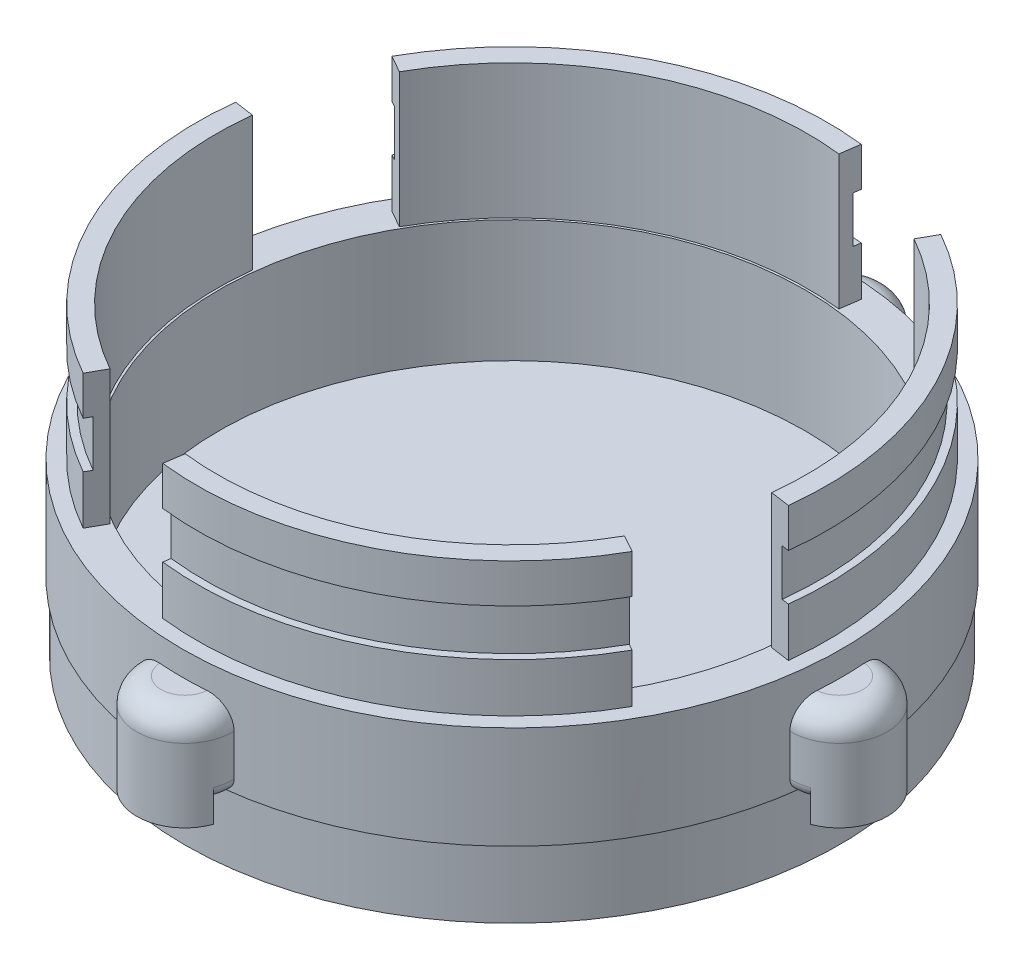
from build123d import *

# Parameters (mm, degrees)
SKETCH3_R             = 34.29
SKETCH3_R_2           = 30.48
BOSS_EXTRUDE2_DEPTH   = 12.7
BOSS_EXTRUDE6_DEPTH   = 26.67
BOSS_EXTRUDE6_2_DEPTH = 26.67
BOSS_EXTRUDE6_3_DEPTH = 26.67
BOSS_EXTRUDE6_4_DEPTH = 26.67
CUT_EXTRUDE2_START    = 17.78
SKETCH7_R             = 34.036
SKETCH7_R_2           = 32.004
CUT_EXTRUDE2_DEPTH    = 4.826
SKETCH8_R             = 34.036
SKETCH8_R_2           = 5
BOSS_EXTRUDE7_DEPTH   = 5.08
BOSS_EXTRUDE8_START   = 10.16
BOSS_EXTRUDE8_DEPTH   = 10.16
FILLET1_R             = 2.54
CUT_EXTRUDE3_START    = 2.032
SKETCH11_R            = 36.068
SKETCH11_R_2          = 34.036
CUT_EXTRUDE3_DEPTH    = 2.032
FILLET2_R             = 1.27


with BuildPart() as part:
    # Sketch3 → Boss-Extrude2 (new body)
    with BuildSketch(Plane(origin=(0, 0, 0), x_dir=(1, 0, 0), z_dir=(0, 1, 0))):
        with Locations(Location((0, 0, 0), (0, 0, 90))):
            Circle(SKETCH3_R)
        with Locations(Location((0, 0, 0), (0, 0, 90))):
            Circle(SKETCH3_R_2, mode=Mode.SUBTRACT)
    extrude(amount=BOSS_EXTRUDE2_DEPTH)



with BuildPart() as body_2:
    # Sketch5 → Boss-Extrude6 (new body)
    with BuildSketch(Plane(origin=(0, 0, 0), x_dir=(1, 0, 0), z_dir=(0, 1, 0))):
        with BuildLine():
            ThreePointArc((28.559021933, -16.062161195), (14.875452714, -29.194719772), (-3.792010539, -32.545835557))
            Line((-3.792010539, -32.545835557), (-3.498056233, -30.513835557))
            ThreePointArc((-3.498056233, -30.513835557), (13.96902765, -27.35318673), (26.770214716, -15.056100486))
            Line((26.770214716, -15.056100486), (28.559021933, -16.062161195))
        make_face()
    extrude(amount=BOSS_EXTRUDE6_DEPTH)


with BuildPart() as body_3:
    # Sketch5 → Boss-Extrude6 2 (new body)
    with BuildSketch(Plane(origin=(0, 0, 0), x_dir=(1, 0, 0), z_dir=(0, 1, 0))):
        with BuildLine():
            ThreePointArc((-28.559021933, 16.062161195), (-14.875452714, 29.194719772), (3.792010539, 32.545835557))
            Line((3.792010539, 32.545835557), (3.498056233, 30.513835557))
            ThreePointArc((3.498056233, 30.513835557), (-13.96902765, 27.35318673), (-26.770214716, 15.056100486))
            Line((-26.770214716, 15.056100486), (-28.559021933, 16.062161195))
        make_face()
    extrude(amount=BOSS_EXTRUDE6_2_DEPTH)


with BuildPart() as body_4:
    # Sketch5 → Boss-Extrude6 3 (new body)
    with BuildSketch(Plane(origin=(0, 0, 0), x_dir=(1, 0, 0), z_dir=(0, 1, 0))):
        with BuildLine():
            ThreePointArc((-16.062161195, -28.559021933), (-29.194719772, -14.875452714), (-32.545835557, 3.792010539))
            Line((-32.545835557, 3.792010539), (-30.513835557, 3.498056233))
            ThreePointArc((-30.513835557, 3.498056233), (-27.35318673, -13.96902765), (-15.056100486, -26.770214716))
            Line((-15.056100486, -26.770214716), (-16.062161195, -28.559021933))
        make_face()
    extrude(amount=BOSS_EXTRUDE6_3_DEPTH)


with BuildPart() as body_5:
    # Sketch5 → Boss-Extrude6 4 (new body)
    with BuildSketch(Plane(origin=(0, 0, 0), x_dir=(1, 0, 0), z_dir=(0, 1, 0))):
        with BuildLine():
            ThreePointArc((30.513835557, -3.498056233), (27.35318673, 13.96902765), (15.056100486, 26.770214716))
            Line((15.056100486, 26.770214716), (16.062161195, 28.559021933))
            ThreePointArc((16.062161195, 28.559021933), (29.194719772, 14.875452714), (32.545835557, -3.792010539))
            Line((32.545835557, -3.792010539), (30.513835557, -3.498056233))
        make_face()
    extrude(amount=BOSS_EXTRUDE6_4_DEPTH)


with BuildPart() as cut_extrude2_tool:
    # Sketch7 → Cut-Extrude2 (new body)
    with BuildSketch(Plane(origin=(0, 0, 0), x_dir=(1, 0, 0), z_dir=(0, 1, 0)).offset(CUT_EXTRUDE2_START)):
        Circle(SKETCH7_R)
        Circle(SKETCH7_R_2, mode=Mode.SUBTRACT)
    extrude(amount=CUT_EXTRUDE2_DEPTH)


with BuildPart() as body_2_1:
    add(body_2.part)

    # Cut-Extrude2: cut by cut_extrude2_tool
    add(cut_extrude2_tool.part, mode=Mode.SUBTRACT)


with BuildPart() as body_3_1:
    add(body_3.part)

    # Cut-Extrude2: cut by cut_extrude2_tool
    add(cut_extrude2_tool.part, mode=Mode.SUBTRACT)


with BuildPart() as body_4_1:
    add(body_4.part)

    # Cut-Extrude2: cut by cut_extrude2_tool
    add(cut_extrude2_tool.part, mode=Mode.SUBTRACT)


with BuildPart() as body_5_1:
    add(body_5.part)

    # Cut-Extrude2: cut by cut_extrude2_tool
    add(cut_extrude2_tool.part, mode=Mode.SUBTRACT)


with BuildPart() as part_1:
    add(part.part)

    add(body_2_1.part)  # Boss-Extrude7 merges body 2

    add(body_3_1.part)  # Boss-Extrude7 merges body 3

    add(body_4_1.part)  # Boss-Extrude7 merges body 4

    add(body_5_1.part)  # Boss-Extrude7 merges body 5
    # Sketch8 → Boss-Extrude7 (add)
    with BuildSketch(Plane(origin=(0, 0, 0), x_dir=(1, 0, 0), z_dir=(0, 1, 0))):
        with Locations(Location((0, 0, 0), (0, 0, 270))):
            Circle(SKETCH8_R)
        with Locations(Location((0, 0, 0), (0, 0, 270))):
            Circle(SKETCH8_R_2, mode=Mode.SUBTRACT)
    extrude(amount=-BOSS_EXTRUDE7_DEPTH)

    # Sketch10 → Boss-Extrude8 (add)
    with BuildSketch(Plane(origin=(0, 0, 0), x_dir=(1, 0, 0), z_dir=(0, 1, 0)).offset(BOSS_EXTRUDE8_START)):
        with BuildLine():
            ThreePointArc((-33.667981618, -4.991623958), (-34.036, 0), (-33.667981618, 4.991623958))
            ThreePointArc((-33.667981618, 4.991623958), (-37.442593016, 3.666997586), (-39.041172052, 0))
            ThreePointArc((-39.041172052, 0), (-37.442593016, -3.666997586), (-33.667981618, -4.991623958))
        make_face()
        with BuildLine():
            ThreePointArc((0, -39.041172052), (3.666997586, -37.442593016), (4.991623958, -33.667981618))
            ThreePointArc((4.991623958, -33.667981618), (0, -34.036), (-4.991623958, -33.667981618))
            ThreePointArc((-4.991623958, -33.667981618), (-3.666997586, -37.442593016), (0, -39.041172052))
        make_face()
        with BuildLine():
            ThreePointArc((33.667981618, 4.991623958), (33.943870716, 2.502586026), (34.036, 0))
            ThreePointArc((34.036, 0), (33.943870716, -2.502586026), (33.667981618, -4.991623958))
            ThreePointArc((33.667981618, -4.991623958), (37.442593016, -3.666997586), (39.041172052, 0))
            ThreePointArc((39.041172052, 0), (37.442593016, 3.666997586), (33.667981618, 4.991623958))
        make_face()
        with BuildLine():
            ThreePointArc((-4.991623958, 33.667981618), (0, 34.036), (4.991623958, 33.667981618))
            ThreePointArc((4.991623958, 33.667981618), (3.666997586, 37.442593016), (0, 39.041172052))
            ThreePointArc((0, 39.041172052), (-3.666997586, 37.442593016), (-4.991623958, 33.667981618))
        make_face()
    extrude(amount=-BOSS_EXTRUDE8_DEPTH)

    # Fillet1
    fillet1_edges = [part_1.edges().sort_by_distance(p)[0] for p in [
        (0, 10.16, 39.041172052),
        (39.041172052, 10.16, 0),
        (0, 10.16, -39.041172052),
        (-39.041172052, 10.16, 0),
    ]]
    fillet(fillet1_edges, radius=FILLET1_R)

    # Sketch11 → Cut-Extrude3 (cut)
    with BuildSketch(Plane(origin=(0, 0, 0), x_dir=(1, 0, 0), z_dir=(0, 1, 0)).offset(CUT_EXTRUDE3_START)):
        Circle(SKETCH11_R)
        with Locations(Location((0, 0, 0), (0, 0, 270))):
            Circle(SKETCH11_R_2, mode=Mode.SUBTRACT)
    extrude(amount=-CUT_EXTRUDE3_DEPTH, mode=Mode.SUBTRACT)

    # Fillet2
    fillet2_edges = [part_1.edges().sort_by_distance(p)[0] for p in [
        (4.937526405, 2.032, -34.856109911),
        (-4.937526405, 2.032, -34.856109911),
        (-34.856109911, 2.032, 4.937526405),
        (-4.937526405, 2.032, 34.856109911),
        (4.937526405, 2.032, 34.856109911),
        (34.856109911, 2.032, 4.937526405),
        (-34.856109911, 2.032, -4.937526405),
        (34.856109911, 2.032, -4.937526405),
    ]]
    fillet(fillet2_edges, radius=FILLET2_R)


solid = part_1.part
